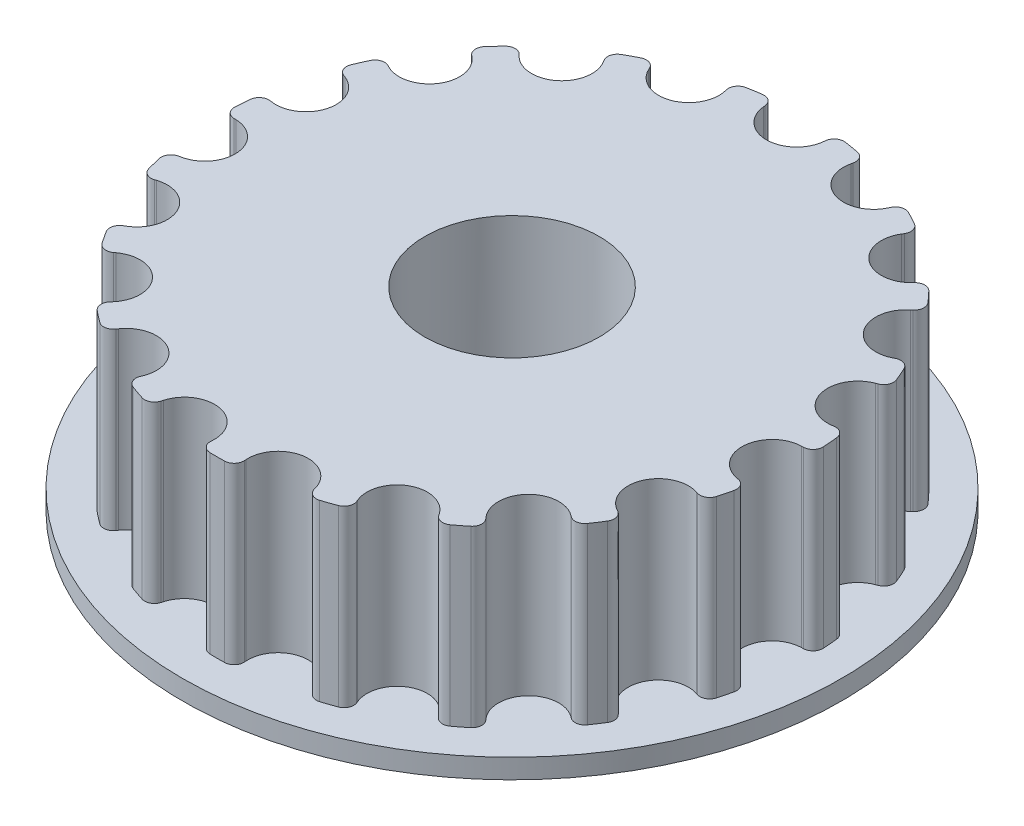
from build123d import *

# Parameters (mm, degrees)
SKETCH_1_R                       = 17
EXTRUDE_1_DEPTH                  = 4.01
SKETCH_3_R                       = 15.205
EXTRUDE_2_DEPTH                  = 9
SKETCH_4_R                       = 4.5
CUT_EXTRUDE_2_DEPTH              = 28.336058604
CUT_EXTRUDE_START                = -9
CUT_EXTRUDE_4_DEPTH              = 9
FILLET_2_R                       = 0.5
PATTERN_CIRCULAR_7_COUNT         = 19
FILLET_2_OF_PATTERN_CIRCULAR_7_R = 0.5
SKETCH_6_R                       = 17
CUT_EXTRUDE_6_DEPTH              = 3
SKETCH_7_R                       = 11.15
CUT_EXTRUDE_7_DEPTH              = 3.6


with BuildPart() as part:
    # Эскиз1 → Бобышка-Вытянуть1 (new body)
    with BuildSketch(Plane(origin=(0, 0, 0), x_dir=(1, 0, 0), z_dir=(0, 1, 0))):
        Circle(SKETCH_1_R)
    extrude(amount=EXTRUDE_1_DEPTH)

    # Эскиз3 → Бобышка-Вытянуть2 (add)
    with BuildSketch(Plane(origin=(0, 4.01, 0), x_dir=(1, 0, 0), z_dir=(0, 1, 0))):
        Circle(SKETCH_3_R)
    extrude(amount=EXTRUDE_2_DEPTH)

    # Эскиз4 → Вырез-Вытянуть2 (cut, through all)
    with BuildSketch(Plane(origin=(0, 13.01, 0), x_dir=(1, 0, 0), z_dir=(0, 1, 0))):
        Circle(SKETCH_4_R)
    extrude(amount=-CUT_EXTRUDE_2_DEPTH, mode=Mode.SUBTRACT)

    # Эскиз5 → Вырез-Вытянуть4 (cut)
    with BuildSketch(Plane(origin=(0, 13.01, 0), x_dir=(1, 0, 0), z_dir=(0, 1, 0)).offset(CUT_EXTRUDE_START)):
        with BuildLine():
            Line((-1.615240041, 15.118962418), (-1.551172735, 14.519279917))
            ThreePointArc((-1.551172735, 14.519279917), (-2e-09, 13.125), (1.551172735, 14.519279913))
            Line((1.551172735, 14.519279913), (1.615240041, 15.118962418))
            ThreePointArc((1.615240041, 15.118962418), (0, 15.205), (-1.615240041, 15.118962418))
        make_face()
    cut_extrude_4 = extrude(amount=CUT_EXTRUDE_4_DEPTH, mode=Mode.SUBTRACT)

    # Скругление2
    fillet_2_edges = [part.edges().sort_by_distance(p)[0] for p in [
        (-1.615240041, 8.51, -15.118962418),
        (1.615240041, 8.51, -15.118962418),
    ]]
    fillet(fillet_2_edges, radius=FILLET_2_R)

    # Круговой массив7: Вырез-Вытянуть4 ×19 about axis
    pattern_circular_7_axis = Axis((0, 0, 0), (0, 1, 0))
    for i in range(1, PATTERN_CIRCULAR_7_COUNT):
        add(cut_extrude_4.rotate(pattern_circular_7_axis, i * 360 / PATTERN_CIRCULAR_7_COUNT), mode=Mode.SUBTRACT)

    # Скругление2 of Круговой массив7
    fillet_2_of_pattern_circular_7_edges = [part.edges().sort_by_distance(p)[0] for p in [
        (-6.436840952, 8.51, -13.775307748),
        (-3.381397192, 8.51, -14.824242916),
        (-10.560910269, 8.51, -10.938884737),
        (-8.011607571, 8.51, -12.923086672),
        (-13.540541088, 8.51, -6.917063831),
        (-11.773635958, 8.51, -9.621513464),
        (-15.052844177, 8.51, -2.145671729),
        (-14.259808201, 8.51, -5.27729998),
        (-14.933938031, 8.51, 2.858237198),
        (-15.200708962, 8.51, -0.361209156),
        (-13.196707975, 8.51, 7.552411775),
        (-14.494377044, 8.51, 4.594024283),
        (-10.029409842, 8.51, 11.428165348),
        (-12.217354469, 8.51, 9.051423909),
        (-5.775269531, 8.51, 14.065499879),
        (-8.616391966, 8.51, 12.527961306),
        (-0.895289153, 8.51, 15.17861925),
        (-4.081709697, 8.51, 14.646899704),
        (4.081709697, 8.51, 14.646899704),
        (0.895289153, 8.51, 15.17861925),
        (8.616391966, 8.51, 12.527961306),
        (5.775269531, 8.51, 14.065499879),
        (12.217354469, 8.51, 9.051423909),
        (10.029409842, 8.51, 11.428165348),
        (14.494377044, 8.51, 4.594024283),
        (13.196707975, 8.51, 7.552411775),
        (15.200708962, 8.51, -0.361209156),
        (14.933938031, 8.51, 2.858237198),
        (14.259808201, 8.51, -5.27729998),
        (15.052844177, 8.51, -2.145671729),
        (11.773635958, 8.51, -9.621513464),
        (13.540541088, 8.51, -6.917063831),
        (8.011607571, 8.51, -12.923086672),
        (10.560910269, 8.51, -10.938884737),
        (3.381397192, 8.51, -14.824242916),
        (6.436840952, 8.51, -13.775307748),
    ]]
    fillet(fillet_2_of_pattern_circular_7_edges, radius=FILLET_2_OF_PATTERN_CIRCULAR_7_R)

    # Эскиз6 → Вырез-Вытянуть6 (cut)
    with BuildSketch(Plane.XZ):
        Circle(SKETCH_6_R)
    extrude(amount=-CUT_EXTRUDE_6_DEPTH, mode=Mode.SUBTRACT)

    # Эскиз7 → Вырез-Вытянуть7 (cut)
    with BuildSketch(Plane.XZ.offset(-3)):
        Circle(SKETCH_7_R)
    extrude(amount=-CUT_EXTRUDE_7_DEPTH, mode=Mode.SUBTRACT)


solid = part.part
